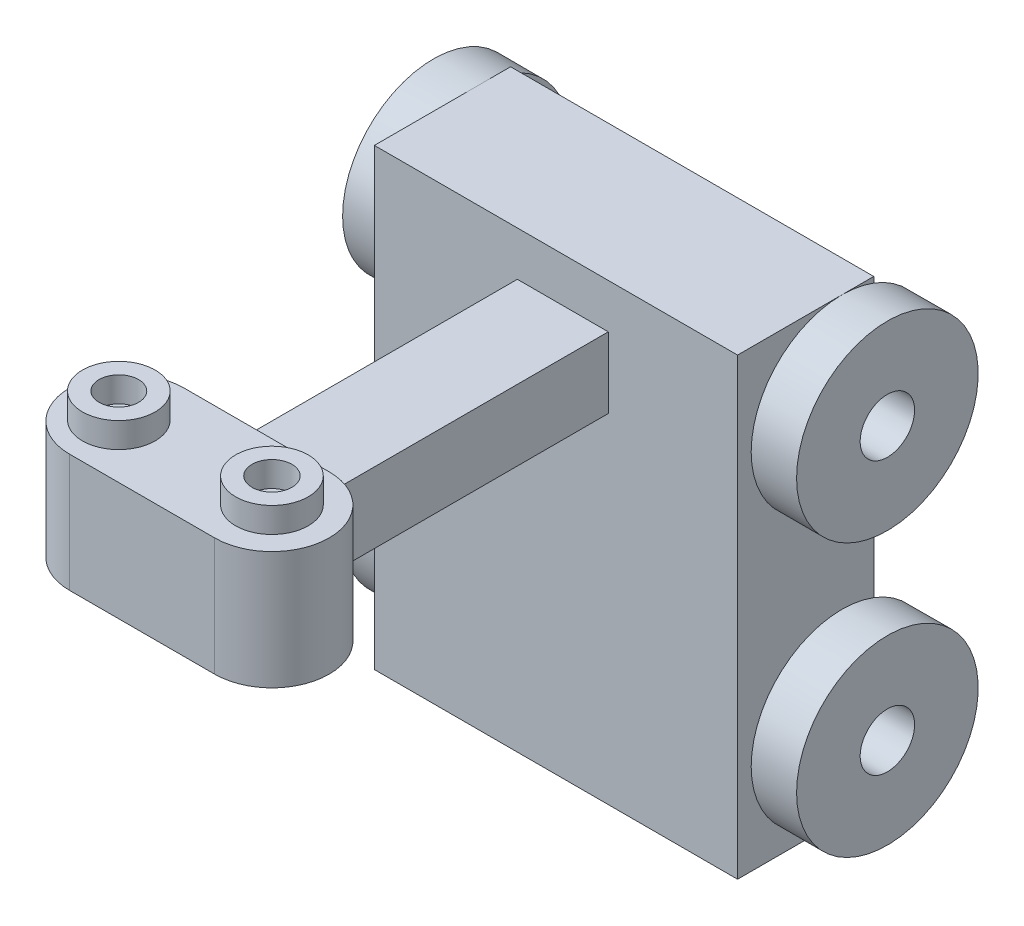
from build123d import *

# Parameters (mm, degrees)
SKETCH2_W                = 4000
SKETCH2_H                = 5000
BOSS_EXTRUDE1_DEPTH      = 1500
SKETCH3_R                = 1000
SKETCH3_R_2              = 300
BOSS_EXTRUDE3_DEPTH      = 500
BOSS_EXTRUDE3_DEPTH_BACK = 4500
SKETCH5_W                = 4000
SKETCH5_H                = 5000
CUT_EXTRUDE1_DEPTH       = 2265
SKETCH6_W                = 1001.71973897
SKETCH6_H                = 779.115352533
BOSS_EXTRUDE4_DEPTH      = 4003
BOSS_EXTRUDE5_DEPTH      = 500
BOSS_EXTRUDE5_DEPTH_BACK = 800
SKETCH8_R                = 400
SKETCH8_R_2              = 217.789034684
SKETCH8_R_3              = 220
BOSS_EXTRUDE6_DEPTH      = 277


with BuildPart() as part:
    # Sketch2 → Boss-Extrude1 (new body)
    with BuildSketch(Plane.XY):
        with Locations((38898.791453363, -206.111128518)):
            Rectangle(SKETCH2_W, SKETCH2_H)
    extrude(amount=BOSS_EXTRUDE1_DEPTH)

    # Sketch3 → Boss-Extrude3 (add, two sides)
    with BuildSketch(Plane.ZY.offset(-36898.791453363)) as boss_extrude3_sk:
        with Locations((350, 1293.888871482)):
            Circle(SKETCH3_R)
        with Locations((350, 1293.888871482)):
            Circle(SKETCH3_R_2, mode=Mode.SUBTRACT)
        with Locations((350, -1706.111128518)):
            Circle(SKETCH3_R)
        with Locations((350, -1706.111128518)):
            Circle(SKETCH3_R_2, mode=Mode.SUBTRACT)
    extrude(amount=BOSS_EXTRUDE3_DEPTH)
    extrude(boss_extrude3_sk.sketch, amount=-BOSS_EXTRUDE3_DEPTH_BACK)

    # Sketch5 → Cut-Extrude1 (cut)
    with BuildSketch(Plane(origin=(0, 0, 0), x_dir=(-1, 0, 0), z_dir=(0, 0, -1))):
        with Locations((-38898.791453363, -206.111128518)):
            Rectangle(SKETCH5_W, SKETCH5_H)
    extrude(amount=CUT_EXTRUDE1_DEPTH, mode=Mode.SUBTRACT)

    # Sketch6 → Boss-Extrude4 (add)
    with BuildSketch(Plane.XY.offset(1500)):
        with Locations((38974.285343741, 1414.354452783)):
            Rectangle(SKETCH6_W, SKETCH6_H)
    extrude(amount=BOSS_EXTRUDE4_DEPTH)

    # Sketch7 → Boss-Extrude5 (add, two sides)
    with BuildSketch(Plane(origin=(0, 1803.912129049, 0), x_dir=(1, 0, 0), z_dir=(0, 1, 0))) as boss_extrude5_sk:
        with BuildLine():
            Line((38175.060305498, -4872.512277543), (39773.510381983, -4872.512277543))
            ThreePointArc((39773.510381983, -4872.512277543), (40403.998104441, -5503), (39773.510381983, -6133.487722457))
            Line((39773.510381983, -6133.487722457), (38175.060305498, -6133.487722457))
            ThreePointArc((38175.060305498, -6133.487722457), (37544.572583041, -5503), (38175.060305498, -4872.512277543))
        make_face()
    extrude(amount=BOSS_EXTRUDE5_DEPTH)
    extrude(boss_extrude5_sk.sketch, amount=-BOSS_EXTRUDE5_DEPTH_BACK)

    # Sketch8 → Boss-Extrude6 (add)
    with BuildSketch(Plane(origin=(0, 2303.912129049, 0), x_dir=(1, 0, 0), z_dir=(0, 1, 0))):
        with Locations((38120.684189959, -5536.755767572)):
            Circle(SKETCH8_R)
        with Locations((38120.684189959, -5536.755767572)):
            Circle(SKETCH8_R_2, mode=Mode.SUBTRACT)
        with Locations((39773.510381983, -5503)):
            Circle(SKETCH8_R)
        with Locations((39773.510381983, -5503)):
            Circle(SKETCH8_R_3, mode=Mode.SUBTRACT)
    extrude(amount=BOSS_EXTRUDE6_DEPTH)


solid = part.part
